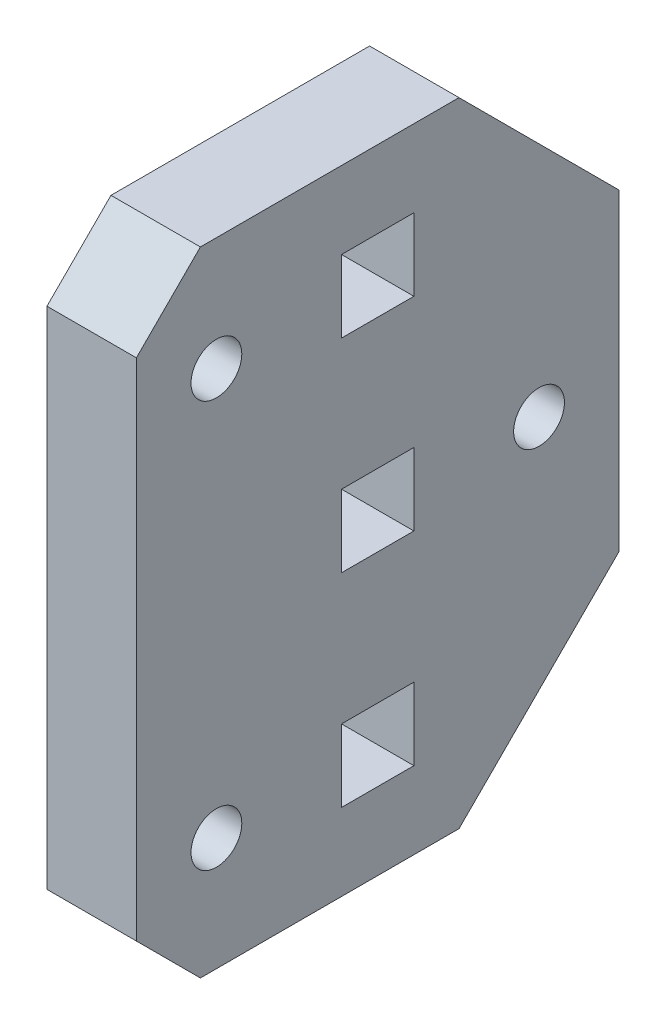
from build123d import *

# Parameters (mm, degrees)
SKETCH1_W           = 30.16
SKETCH1_H           = 39.56
SKETCH1_R           = 1.5875
SKETCH1_W_2         = 4.521190227
SKETCH1_H_2         = 4.521190227
SKETCH1_W_3         = 4.521190228
SKETCH1_H_3         = 4.521190228
BOSS_EXTRUDE1_DEPTH = 5.588
CHAMFER1_SIZE       = 10
CHAMFER2_SIZE       = 4


with BuildPart() as part:
    # Sketch1 → Boss-Extrude1 (new body)
    with BuildSketch(Plane(origin=(0, 0, 0), x_dir=(0, 0, -1), z_dir=(1, 0, 0))):
        with Locations((4.886e-06, 4.886e-06)):
            Rectangle(SKETCH1_W, SKETCH1_H)
        with Locations((-10.079995114, 12.700004886)):
            Circle(SKETCH1_R, mode=Mode.SUBTRACT)
        with Locations((-10.079995114, -12.699995114)):
            Circle(SKETCH1_R, mode=Mode.SUBTRACT)
        with Locations((10.080004886, 0)):
            Circle(SKETCH1_R, mode=Mode.SUBTRACT)
        with Locations((4.886e-06, 12.700004887)):
            Rectangle(SKETCH1_W_2, SKETCH1_H_2, mode=Mode.SUBTRACT)
        Rectangle(SKETCH1_W_3, SKETCH1_H_3, mode=Mode.SUBTRACT)
        with Locations((4.886e-06, -12.699995114)):
            Rectangle(SKETCH1_W_2, SKETCH1_H_2, mode=Mode.SUBTRACT)
    extrude(amount=BOSS_EXTRUDE1_DEPTH)

    # Chamfer1
    chamfer1_edges = [part.edges().sort_by_distance(p)[0] for p in [
        (2.794, -19.779995114, -15.080004886),
        (2.794, 19.780004886, -15.080004886),
    ]]
    chamfer(chamfer1_edges, length=CHAMFER1_SIZE)

    # Chamfer2
    chamfer2_edges = [part.edges().sort_by_distance(p)[0] for p in [
        (2.794, 19.780004886, 15.079995114),
        (2.794, -19.779995114, 15.079995114),
    ]]
    chamfer(chamfer2_edges, length=CHAMFER2_SIZE)


solid = part.part
